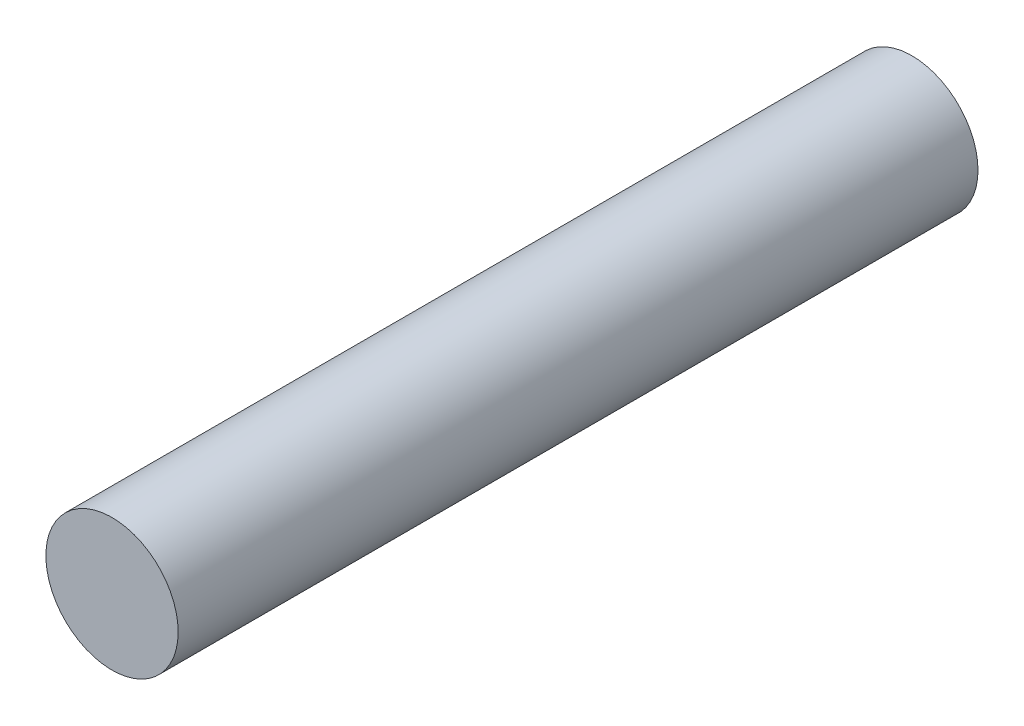
from build123d import *

# Parameters (mm, degrees)
CROQUIS1_R              = 2.15
SALIENTE_EXTRUIR1_DEPTH = 26


with BuildPart() as part:
    # Croquis1 → Saliente-Extruir1 (new body)
    with BuildSketch(Plane.XY):
        Circle(CROQUIS1_R)
    extrude(amount=SALIENTE_EXTRUIR1_DEPTH)


solid = part.part
